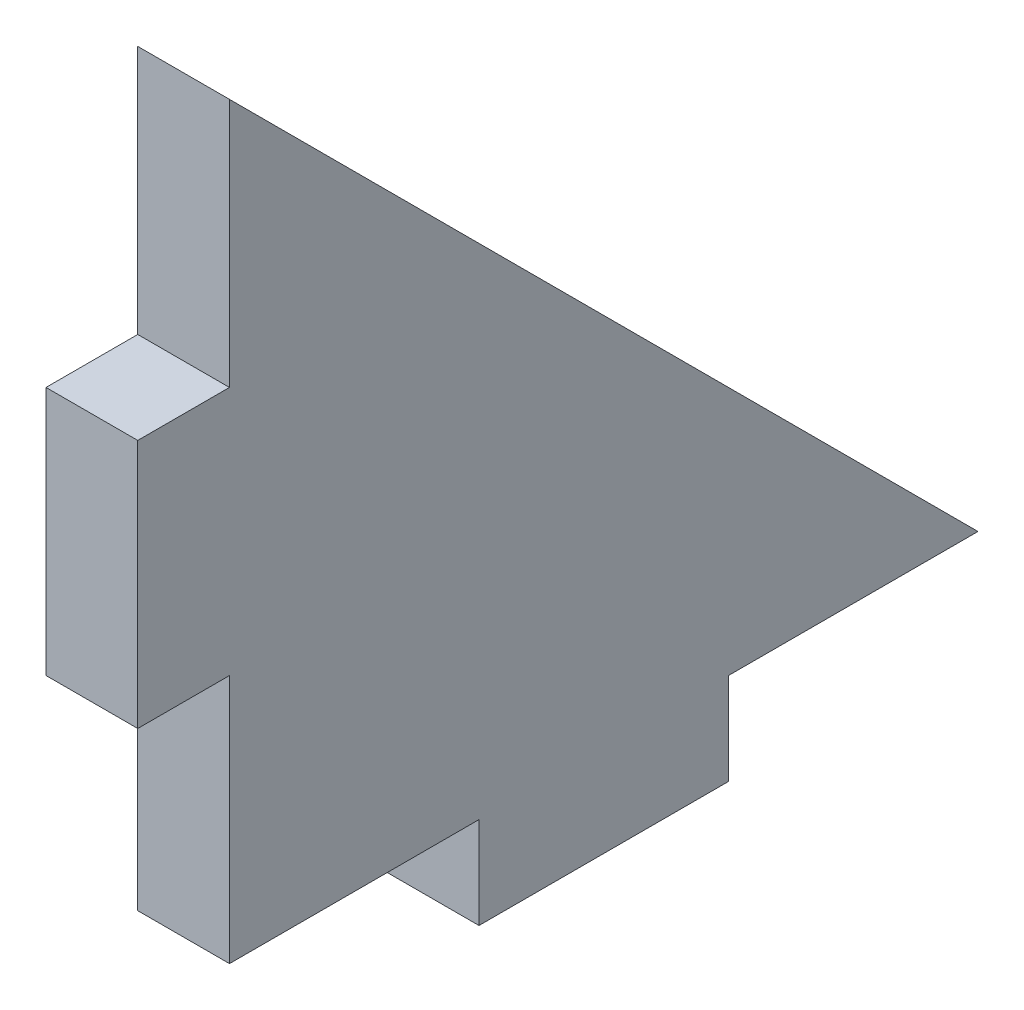
from build123d import *

# Parameters (mm, degrees)
BOSS_EXTRUDE1_DEPTH = 2.6


with BuildPart() as part:
    # Sketch1 → Boss-Extrude1 (new body)
    with BuildSketch(Plane(origin=(0, 0, 0), x_dir=(0, 0, -1), z_dir=(1, 0, 0))):
        Polygon((0, 21.213203436), (21.213203436, 0), (14.142135624, 0), (14.142135624, -2.6), (7.071067812, -2.6), (7.071067812, 0), (0, 0), (0, 7.071067812), (-2.6, 7.071067812), (-2.6, 14.142135624), (0, 14.142135624), align=None)
    extrude(amount=BOSS_EXTRUDE1_DEPTH)


solid = part.part
